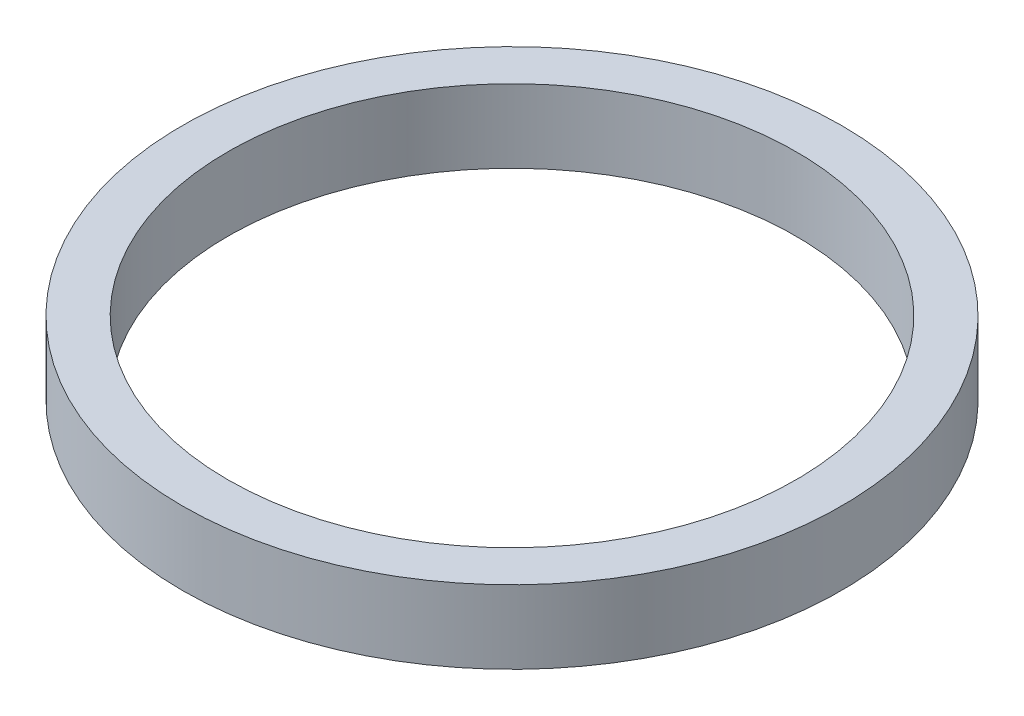
from build123d import *

# Parameters (mm, degrees)
SKETCH1_R           = 57.15
BOSS_EXTRUDE1_DEPTH = 12.7
SKETCH2_R           = 49.276
CUT_EXTRUDE1_DEPTH  = 12.7


with BuildPart() as part:
    # Sketch1 → Boss-Extrude1 (new body)
    with BuildSketch(Plane(origin=(0, 0, 0), x_dir=(1, 0, 0), z_dir=(0, 1, 0))):
        Circle(SKETCH1_R)
    extrude(amount=BOSS_EXTRUDE1_DEPTH)

    # Sketch2 → Cut-Extrude1 (cut)
    with BuildSketch(Plane(origin=(0, 12.7, 0), x_dir=(1, 0, 0), z_dir=(0, 1, 0))):
        Circle(SKETCH2_R)
    extrude(amount=-CUT_EXTRUDE1_DEPTH, mode=Mode.SUBTRACT)


solid = part.part
